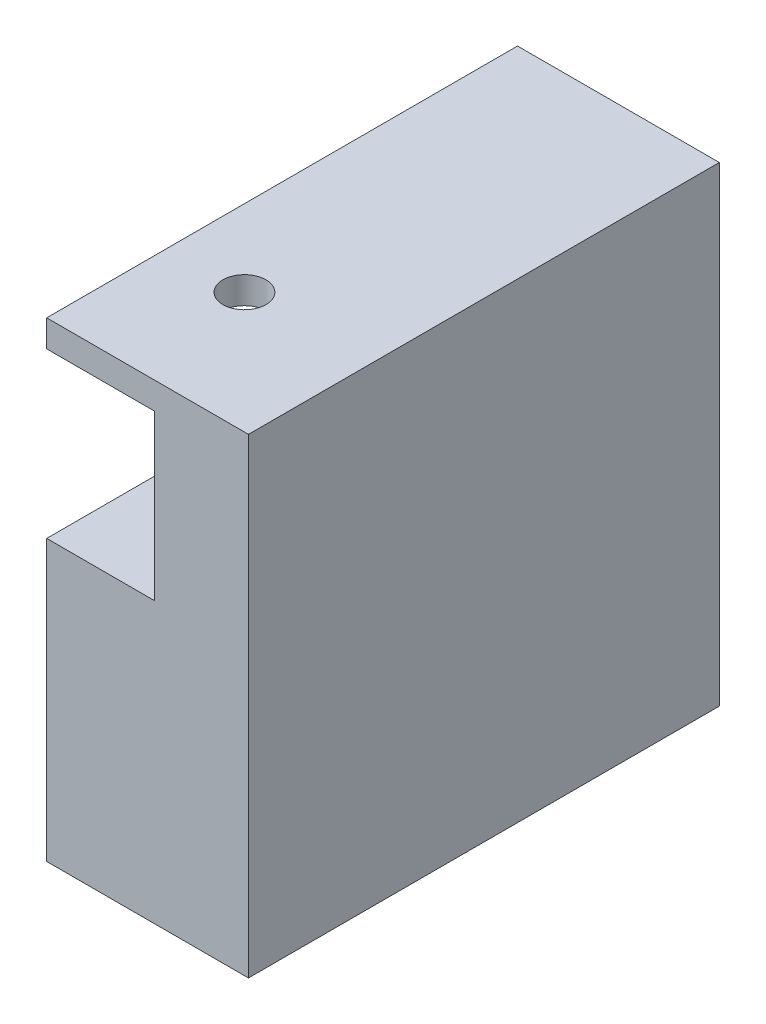
from build123d import *

# Parameters (mm, degrees)
SKETCH1_W           = 15
SKETCH1_H           = 35
BOSS_EXTRUDE1_DEPTH = 35
SKETCH3_W           = 8
SKETCH3_H           = 12.2
CUT_EXTRUDE2_DEPTH  = 18
SKETCH4_R           = 1.6
CUT_EXTRUDE3_DEPTH  = 8


with BuildPart() as part:
    # Sketch1 → Boss-Extrude1 (new body)
    with BuildSketch(Plane(origin=(0, 0, 0), x_dir=(1, 0, 0), z_dir=(0, 1, 0))):
        Rectangle(SKETCH1_W, SKETCH1_H)
    extrude(amount=BOSS_EXTRUDE1_DEPTH)

    # Sketch3 → Cut-Extrude2 (cut)
    with BuildSketch(Plane.XY.offset(17.5)):
        with Locations((-3.5, 26.9)):
            Rectangle(SKETCH3_W, SKETCH3_H)
    extrude(amount=-CUT_EXTRUDE2_DEPTH, mode=Mode.SUBTRACT)

    # Sketch4 → Cut-Extrude3 (cut)
    with BuildSketch(Plane(origin=(0, 35, 0), x_dir=(1, 0, 0), z_dir=(0, 1, 0))):
        with Locations(Location((-1.8, -8.5, 0), (0, 0, 270))):  # turned: the seam where the file's is
            Circle(SKETCH4_R)
    extrude(amount=-CUT_EXTRUDE3_DEPTH, mode=Mode.SUBTRACT)


solid = part.part
